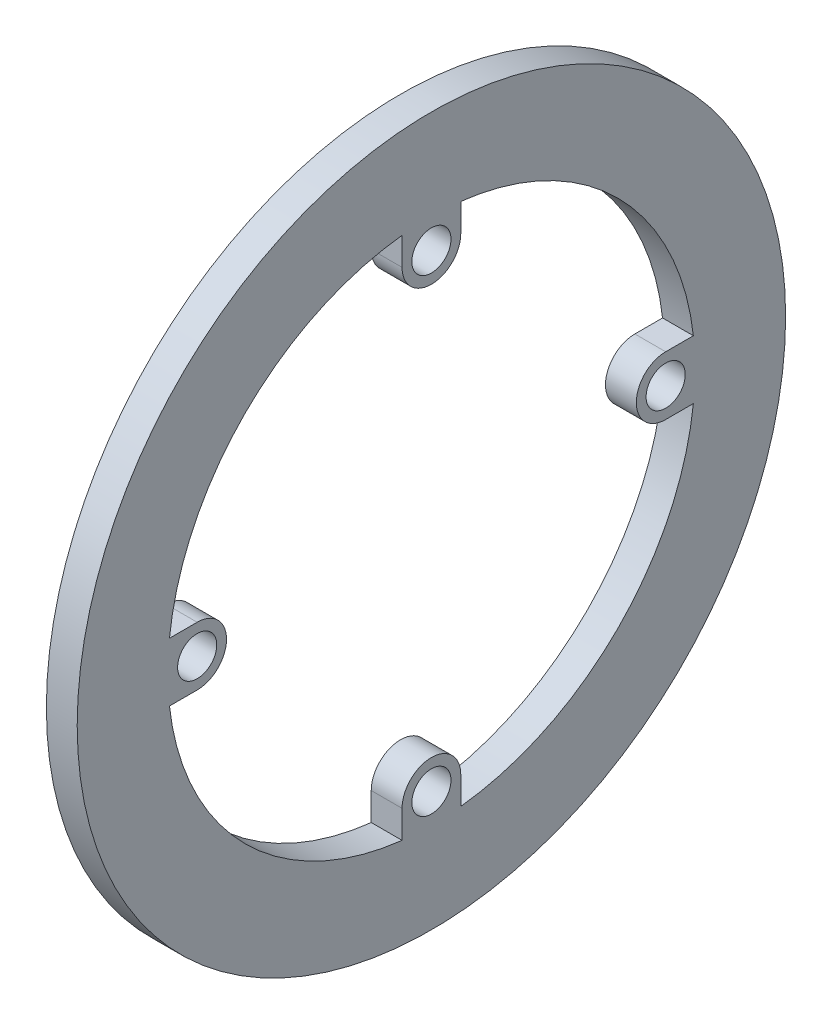
from build123d import *

# Parameters (mm, degrees)
SKETCH1_R           = 57.463033318
SKETCH1_R_2         = 42.7625
SKETCH1_R_3         = 3.175
BOSS_EXTRUDE1_DEPTH = 2.5


with BuildPart() as part:
    # Sketch1 → Boss-Extrude1 (new body, symmetric)
    with BuildSketch(Plane(origin=(0, 0, 0), x_dir=(0, 0, -1), z_dir=(1, 0, 0))):
        Circle(SKETCH1_R)
        Circle(SKETCH1_R_2, mode=Mode.SUBTRACT)
        with BuildLine():
            Line((-38, 4.7625), (-42.496470442, 4.7625))
            ThreePointArc((-42.496470442, 4.7625), (-42.7625, 0), (-42.496470442, -4.7625))
            Line((-42.496470442, -4.7625), (-38, -4.7625))
            ThreePointArc((-38, -4.7625), (-33.2375, 0), (-38, 4.7625))
        make_face()
        with Locations((-38, 0)):
            Circle(SKETCH1_R_3, mode=Mode.SUBTRACT)
        with BuildLine():
            ThreePointArc((4.7625, 42.496470442), (0, 42.7625), (-4.7625, 42.496470442))
            Line((-4.7625, 42.496470442), (-4.7625, 38))
            ThreePointArc((-4.7625, 38), (0, 33.2375), (4.7625, 38))
            Line((4.7625, 38), (4.7625, 42.496470442))
        make_face()
        with Locations((0, 38)):
            Circle(SKETCH1_R_3, mode=Mode.SUBTRACT)
        with BuildLine():
            ThreePointArc((42.7625, 0), (42.695940811, 2.384962158), (42.496470442, 4.7625))
            Line((42.496470442, 4.7625), (38, 4.7625))
            ThreePointArc((38, 4.7625), (33.2375, 0), (38, -4.7625))
            Line((38, -4.7625), (42.496470442, -4.7625))
            ThreePointArc((42.496470442, -4.7625), (42.695940811, -2.384962158), (42.7625, 0))
        make_face()
        with Locations((38, 0)):
            Circle(SKETCH1_R_3, mode=Mode.SUBTRACT)
        with BuildLine():
            Line((-4.7625, -38), (-4.7625, -42.496470442))
            ThreePointArc((-4.7625, -42.496470442), (0, -42.7625), (4.7625, -42.496470442))
            Line((4.7625, -42.496470442), (4.7625, -38))
            ThreePointArc((4.7625, -38), (0, -33.2375), (-4.7625, -38))
        make_face()
        with Locations((0, -38)):
            Circle(SKETCH1_R_3, mode=Mode.SUBTRACT)
    extrude(amount=BOSS_EXTRUDE1_DEPTH, both=True)


solid = part.part
